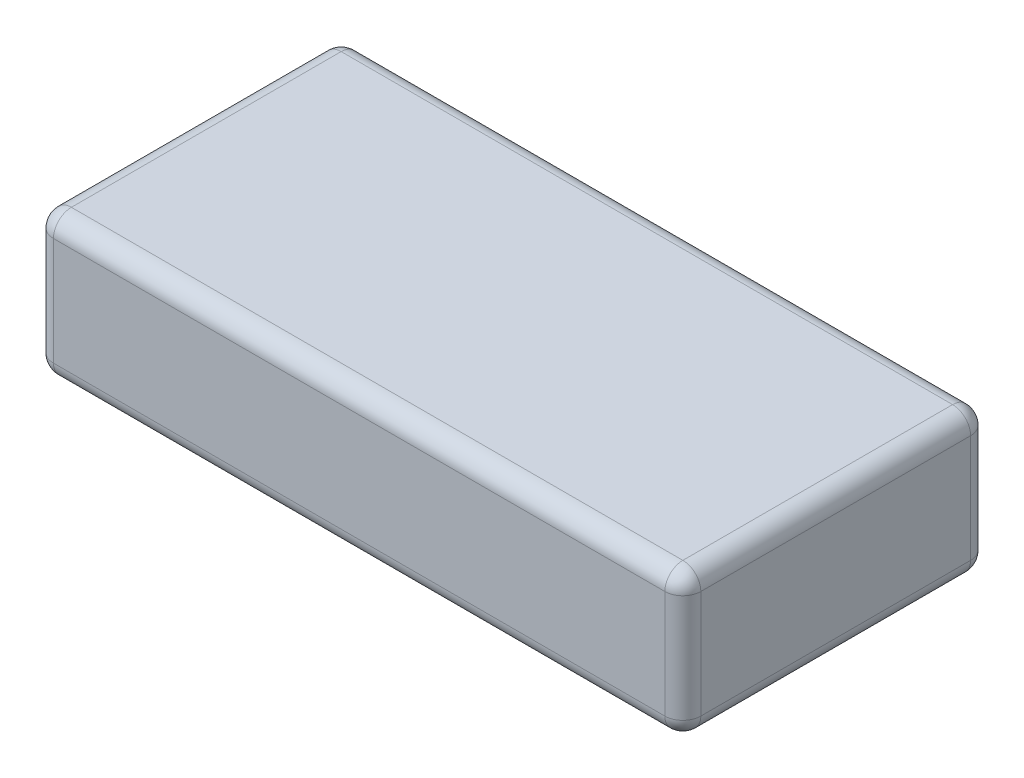
from build123d import *

# Parameters (mm, degrees)
SKETCH1_W           = 72
SKETCH1_H           = 34
BOSS_EXTRUDE1_DEPTH = 16
FILLET1_R           = 2


with BuildPart() as part:
    # Sketch1 → Boss-Extrude1 (new body)
    with BuildSketch(Plane(origin=(0, 0, 0), x_dir=(1, 0, 0), z_dir=(0, 1, 0))):
        with Locations((-3.261405989, -8.758806046)):
            Rectangle(SKETCH1_W, SKETCH1_H)
    extrude(amount=BOSS_EXTRUDE1_DEPTH)

    # Fillet1
    fillet1_edges = [part.edges().sort_by_distance(p)[0] for p in [
        (-39.261405989, 16, 8.758806046),
        (-3.261405989, 16, 25.758806046),
        (32.738594011, 16, 8.758806046),
        (-3.261405989, 0, 25.758806046),
        (-39.261405989, 0, 8.758806046),
        (-3.261405989, 0, -8.241193954),
        (32.738594011, 0, 8.758806046),
        (-3.261405989, 16, -8.241193954),
        (32.738594011, 8, 25.758806046),
        (-39.261405989, 8, 25.758806046),
        (-39.261405989, 8, -8.241193954),
        (32.738594011, 8, -8.241193954),
    ]]
    fillet(fillet1_edges, radius=FILLET1_R)


solid = part.part
